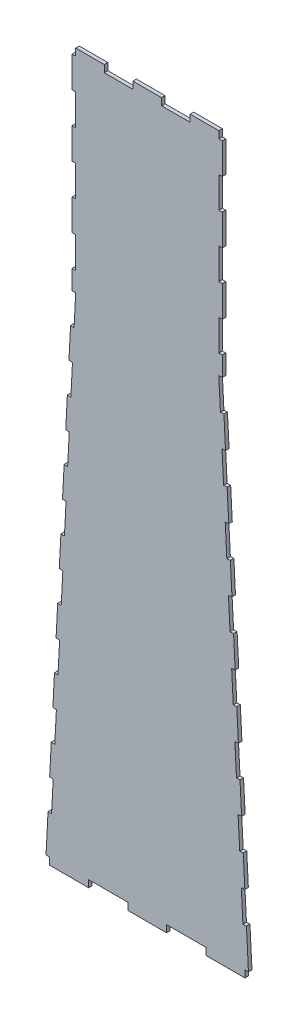
from build123d import *

# Parameters (mm, degrees)
BOSS_EXTRUDE3_DEPTH = 10.16


with BuildPart() as part:
    # Sketch4 → Boss-Extrude3 (new body)
    with BuildSketch(Plane.XY):
        Polygon((-210.367858706, 1373.732193279), (-220.506832234, 1374.260391019), (-225.131875264, 1285.480782003), (-214.992901736, 1284.952584263), (-219.617944766, 1196.172975248), (-229.756918293, 1196.701172988), (-234.381961323, 1107.921563972), (-224.242987795, 1107.393366232), (-228.868030825, 1018.613757216), (-228.874436508, 1018.614090925), (-239.007004353, 1019.141954956), (-243.632047383, 930.362345941), (-233.493073855, 929.834148201), (-238.118116884, 841.054539185), (-248.257090412, 841.582736925), (-252.882133442, 752.803127909), (-242.743159914, 752.274930169), (-247.368202944, 663.495321154), (-247.374608626, 663.495654863), (-257.507176472, 664.023518894), (-262.132219501, 575.243909878), (-251.993245973, 574.715712138), (-256.618289003, 485.936103122), (-266.757262531, 486.464300862), (-271.382305561, 397.684691847), (-261.243332033, 397.156494107), (-265.868375062, 308.376885091), (-276.00734859, 308.905082831), (-280.63239162, 220.125473815), (-270.493418092, 219.597276075), (-275.118461122, 130.81766706), (-285.25743465, 131.3458648), (-291.041413739, 20.32), (-280.874923338, 20.32), (-280.874923338, 0), (-168.302123338, 0), (-168.302123338, 20.32), (-55.729323338, 20.32), (-55.729323338, 0), (55.729323338, 0), (55.729323338, 20.32), (168.302123338, 20.32), (168.302123338, 0), (280.874923338, 0), (280.874923338, 20.32), (291.041413739, 20.32), (285.25743465, 131.3458648), (275.118461122, 130.81766706), (270.493418092, 219.597276075), (280.63239162, 220.125473815), (276.00734859, 308.905082831), (265.868375062, 308.376885091), (261.243332033, 397.156494107), (271.382305561, 397.684691847), (266.757262531, 486.464300862), (256.618289003, 485.936103122), (251.993245973, 574.715712138), (262.132219501, 575.243909878), (257.507176472, 664.023518894), (247.368202944, 663.495321154), (242.743159914, 752.274930169), (252.882133442, 752.803127909), (248.257090412, 841.582736925), (238.118116884, 841.054539185), (233.493073855, 929.834148201), (243.632047383, 930.362345941), (239.007004353, 1019.141954956), (228.868030825, 1018.613757216), (224.242987795, 1107.393366232), (234.381961323, 1107.921563972), (229.756918293, 1196.701172988), (219.617944766, 1196.172975248), (214.992901736, 1284.952584263), (214.999307419, 1284.952917972), (225.131875264, 1285.480782003), (220.506832234, 1374.260391019), (210.367858706, 1373.732193279), (205.715298803, 1463.040000035), (215.881789204, 1463.040000035), (215.881789204, 1518.92), (205.715298803, 1518.92), (205.715298803, 1607.82), (215.881789204, 1607.82), (215.881789204, 1696.72), (205.715298803, 1696.72), (205.715298803, 1785.62), (215.881789204, 1785.62), (215.881789204, 1874.52), (205.715298803, 1874.52), (205.715298803, 1963.42), (215.881789204, 1963.42), (215.881789204, 2052.32), (205.715298803, 2052.32), (205.715298803, 2072.64), (123.444, 2072.64), (123.444, 2052.32), (41.135649402, 2052.32), (41.135649402, 2072.64), (-41.135649402, 2072.64), (-41.135649402, 2052.32), (-123.444, 2052.32), (-123.444, 2072.64), (-205.715298803, 2072.64), (-205.715298803, 2052.32), (-215.881789204, 2052.32), (-215.881789204, 1963.42), (-205.715298803, 1963.42), (-205.715298803, 1874.52), (-215.881789204, 1874.52), (-215.881789204, 1785.62), (-205.715298803, 1785.62), (-205.715298803, 1696.72), (-215.881789204, 1696.72), (-215.881789204, 1607.82), (-205.715298803, 1607.82), (-205.715298803, 1518.92), (-215.881789204, 1518.92), (-215.881789204, 1463.040000035), (-205.715298803, 1463.040000035), align=None)
    extrude(amount=BOSS_EXTRUDE3_DEPTH)


solid = part.part
